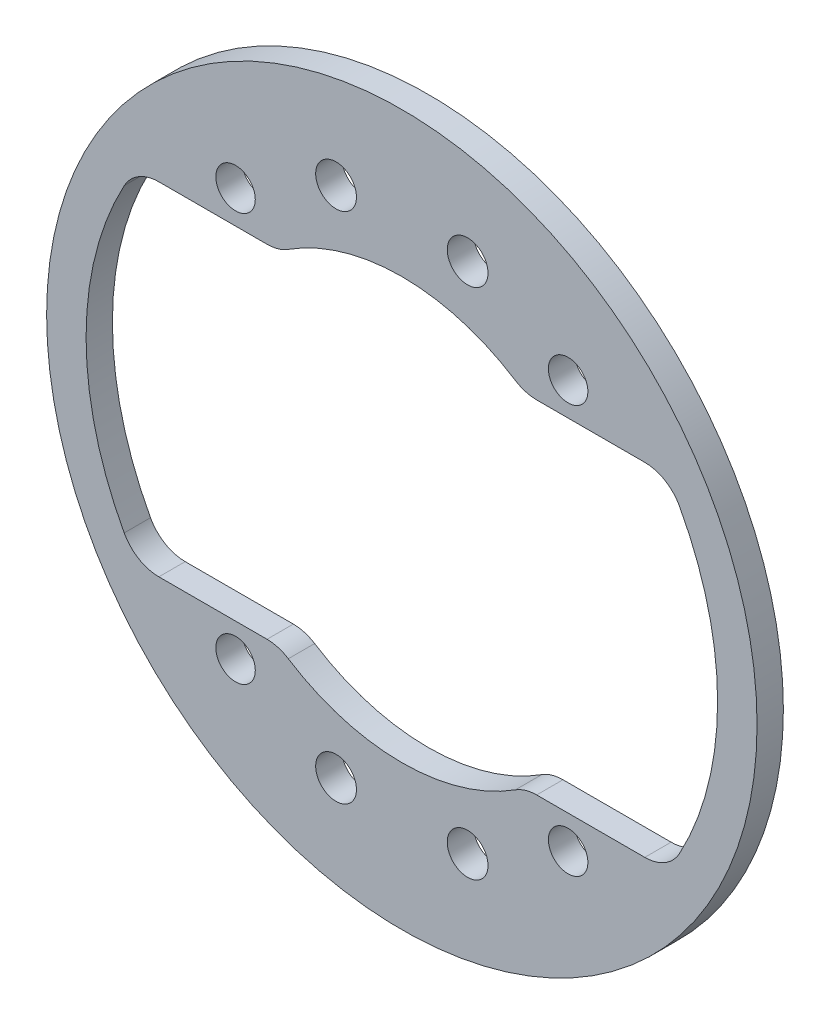
from build123d import *

# Parameters (mm, degrees)
SKETCH_1_R          = 27
SKETCH_1_R_2        = 1.5
EXTRUDE_1_DEPTH     = 1
FILLET_1_R          = 3
SKETCH_2_R          = 1.55
CUT_EXTRUDE_1_DEPTH = 3


with BuildPart() as part:
    # 草图1 → 凸台-拉伸1 (new body, symmetric)
    with BuildSketch(Plane.XY):
        Circle(SKETCH_1_R)
        with Locations((-12.63922466, 15.5)):
            Circle(SKETCH_1_R_2, mode=Mode.SUBTRACT)
        with Locations((12.63922466, 15.5)):
            Circle(SKETCH_1_R_2, mode=Mode.SUBTRACT)
        with Locations((-12.63922466, -15.5)):
            Circle(SKETCH_1_R_2, mode=Mode.SUBTRACT)
        with Locations((12.63922466, -15.5)):
            Circle(SKETCH_1_R_2, mode=Mode.SUBTRACT)
        with BuildLine():
            Line((-20.174241002, 13), (-9.327379053, 13))
            ThreePointArc((-9.327379053, 13), (0, 16), (9.327379053, 13))
            Line((9.327379053, 13), (20.174241002, 13))
            ThreePointArc((20.174241002, 13), (24, 0), (20.174241002, -13))
            Line((20.174241002, -13), (9.327379053, -13))
            ThreePointArc((9.327379053, -13), (0, -16), (-9.327379053, -13))
            Line((-9.327379053, -13), (-20.174241002, -13))
            ThreePointArc((-20.174241002, -13), (-24, 0), (-20.174241002, 13))
        make_face(mode=Mode.SUBTRACT)
    extrude(amount=EXTRUDE_1_DEPTH, both=True)

    # 圆角1
    fillet_1_edges = [part.edges().sort_by_distance(p)[0] for p in [
        (-20.174241002, 13, 0),
        (-20.174241002, -13, 0),
        (-9.327379053, -13, 0),
        (9.327379053, -13, 0),
        (20.174241002, -13, 0),
        (20.174241002, 13, 0),
        (9.327379053, 13, 0),
        (-9.327379053, 13, 0),
    ]]
    fillet(fillet_1_edges, radius=FILLET_1_R)

    # 草图2 → 切除-拉伸1 (cut, through all)
    with BuildSketch(Plane.XY.offset(1)):
        with Locations((-5, 19.5)):
            Circle(SKETCH_2_R)
        with Locations((5, 19.5)):
            Circle(SKETCH_2_R)
        with Locations((-5, -19.5)):
            Circle(SKETCH_2_R)
        with Locations((5, -19.5)):
            Circle(SKETCH_2_R)
    extrude(amount=-CUT_EXTRUDE_1_DEPTH, mode=Mode.SUBTRACT)


solid = part.part
